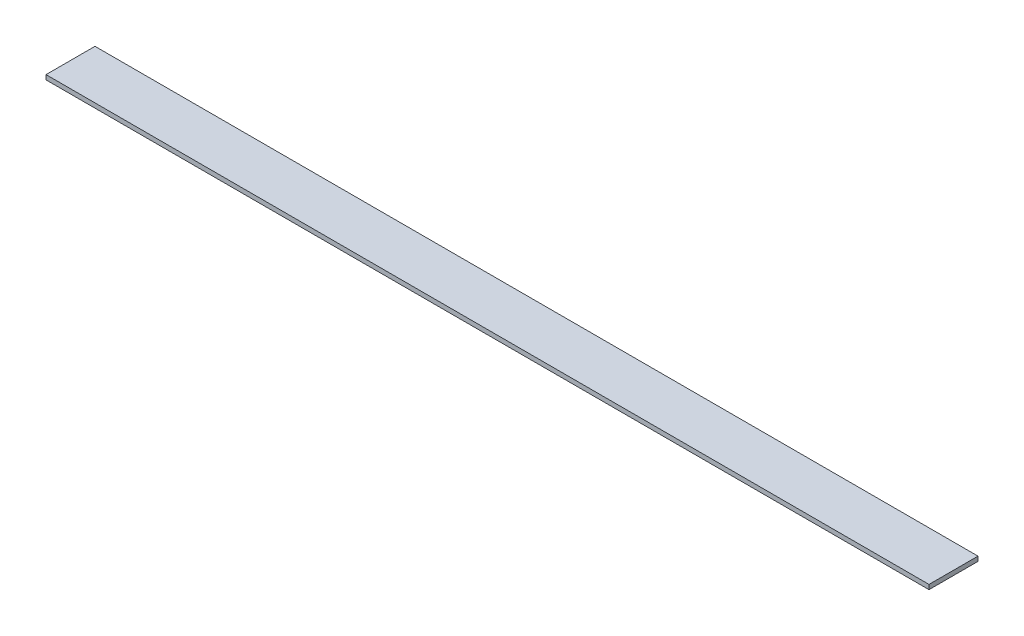
from build123d import *

# Parameters (mm, degrees)
SKETCH1_W           = 612.775
SKETCH1_H           = 34
BOSS_EXTRUDE1_DEPTH = 3.175


with BuildPart() as part:
    # Sketch1 → Boss-Extrude1 (new body)
    with BuildSketch(Plane(origin=(0, 0, 0), x_dir=(1, 0, 0), z_dir=(0, 1, 0))):
        with Locations((306.3875, 17)):
            Rectangle(SKETCH1_W, SKETCH1_H)
    extrude(amount=BOSS_EXTRUDE1_DEPTH)


solid = part.part
